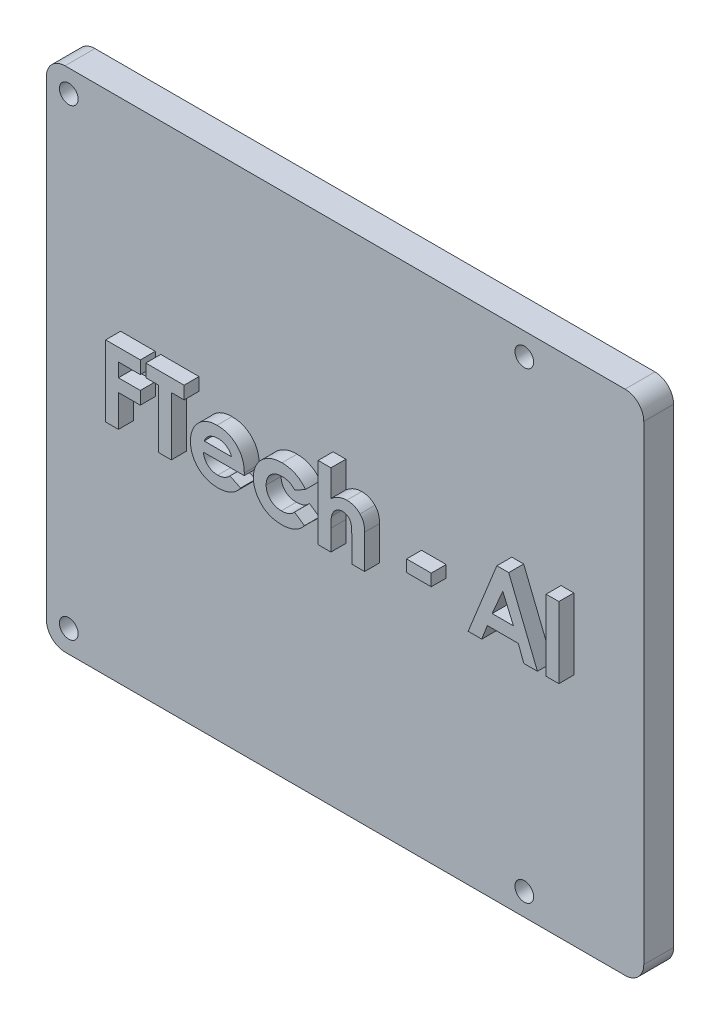
from build123d import *

# Parameters (mm, degrees)
SKETCH1_W           = 80
SKETCH1_H           = 68
BOSS_EXTRUDE1_DEPTH = 4
SKETCH2_W           = 3.297115384
SKETCH2_H           = 1.5875
SKETCH2_W_2         = 1.709615384
SKETCH2_H_2         = 9.525
BOSS_EXTRUDE2_DEPTH = 2
SKETCH3_R           = 1.25
CUT_EXTRUDE1_DEPTH  = 10
FILLET1_R           = 2.5


with BuildPart() as part:
    # Sketch1 → Boss-Extrude1 (new body)
    with BuildSketch(Plane.XY):
        with Locations((40, -34)):
            Rectangle(SKETCH1_W, SKETCH1_H)
    extrude(amount=BOSS_EXTRUDE1_DEPTH)

    # Sketch2 → Boss-Extrude2 (add)
    with BuildSketch(Plane.XY.offset(4)):
        Polygon((9.941146253, -27.067496964), (14.581530868, -27.067496964), (14.581530868, -28.777112348), (11.650761637, -28.777112348), (11.650761637, -30.608843117), (14.581530868, -30.608843117), (14.581530868, -32.318458502), (11.650761637, -32.318458502), (11.650761637, -36.592496964), (9.941146253, -36.592496964), align=None)
        Polygon((15.314223176, -27.067496964), (20.44306933, -27.067496964), (20.44306933, -28.777112348), (18.733453945, -28.777112348), (18.733453945, -36.592496964), (17.02383856, -36.592496964), (17.02383856, -28.777112348), (15.314223176, -28.777112348), align=None)
        with BuildLine():
            Line((28.496960556, -33.539612348), (23.007492406, -33.539612348))
            add(Edge.make_bspline(
                [(23.007492406, -33.539612348), (23.018684989, -33.603396854), (23.040679296, -33.72873844), (23.088440716, -33.910807969), (23.149391451, -34.082387221), (23.222437069, -34.243705554), (23.306346021, -34.395615795), (23.404218861, -34.537405426), (23.514814163, -34.668949208), (23.637492493, -34.789675439), (23.770209026, -34.897848759), (23.912320137, -34.992615425), (24.063972474, -35.070318294), (24.223427402, -35.13581375), (24.391876415, -35.187692785), (24.569567428, -35.22347277), (24.756029409, -35.244608138), (24.883053007, -35.247665127), (24.94798219, -35.249227733)],
                knots=[0, 0, 0, 0, 0.000194219, 0.000381655, 0.000563912, 0.000739826, 0.000912365, 0.001083845, 0.001255835, 0.001427188, 0.001599432, 0.001768776, 0.001938603, 0.002109744, 0.002285378, 0.002466493, 0.00265276, 0.002847531, 0.002847531, 0.002847531, 0.002847531], degree=3))
            add(Edge.make_bspline(
                [(24.94798219, -35.249227733), (25.026356122, -35.247158585), (25.180697476, -35.243083824), (25.406808708, -35.206946748), (25.625491206, -35.152363282), (25.834675464, -35.071193087), (26.036784552, -34.970150463), (26.228491135, -34.844263786), (26.413113502, -34.697211877), (26.525754903, -34.583864321), (26.583183512, -34.52607569)],
                knots=[0, 0, 0, 0, 0.00023497, 0.000462724, 0.000685321, 0.000909986, 0.001134407, 0.001361978, 0.001596793, 0.001841031, 0.001841031, 0.001841031, 0.001841031], degree=3))
            Line((26.583183512, -34.52607569), (28.014223176, -35.207250569))
            add(Edge.make_bspline(
                [(28.014223176, -35.207250569), (27.969167727, -35.269510284), (27.879892013, -35.39287562), (27.734152405, -35.566482509), (27.582063844, -35.728464779), (27.423512902, -35.877757048), (27.258298498, -36.013933893), (27.086880218, -36.138654193), (26.906752853, -36.248569258), (26.721518018, -36.348996714), (26.527346566, -36.435092705), (26.324775856, -36.508512328), (26.114663887, -36.574883042), (25.8943574, -36.62545389), (25.665690885, -36.665485362), (25.428117326, -36.693913009), (25.181668035, -36.711471405), (25.014157888, -36.713552931), (24.928901661, -36.714612348)],
                knots=[0, 0, 0, 0, 0.000230496, 0.000456719, 0.000679438, 0.000896764, 0.001109552, 0.001321381, 0.001532132, 0.00174213, 0.001953106, 0.002168615, 0.002388298, 0.002613691, 0.002846137, 0.00308446, 0.003331197, 0.00358694, 0.00358694, 0.00358694, 0.00358694], degree=3))
            add(Edge.make_bspline(
                [(24.928901661, -36.714612348), (24.797736356, -36.711938282), (24.540856666, -36.706701278), (24.165123683, -36.658094386), (23.808281562, -36.577498918), (23.469322706, -36.467941759), (23.149712321, -36.323291987), (22.849292231, -36.146373316), (22.56506081, -35.940577633), (22.305702913, -35.701585832), (22.069420218, -35.441457465), (21.861884189, -35.162097362), (21.688220996, -34.865457307), (21.545605289, -34.553500525), (21.434759407, -34.22542853), (21.354845956, -33.881098157), (21.305858053, -33.520673865), (21.300567116, -33.275184689), (21.297877022, -33.15036956)],
                knots=[0, 0, 0, 0, 0.000393355, 0.000770363, 0.001134197, 0.001489592, 0.001837156, 0.002184364, 0.002533949, 0.002887809, 0.003240386, 0.003586896, 0.003929847, 0.004269674, 0.004614208, 0.004966883, 0.005328755, 0.005703044, 0.005703044, 0.005703044, 0.005703044], degree=3))
            add(Edge.make_bspline(
                [(21.297877022, -33.15036956), (21.300593592, -33.022382718), (21.305938322, -32.770574356), (21.35442417, -32.401827702), (21.43498034, -32.049993519), (21.546150471, -31.714587295), (21.68660268, -31.394560022), (21.862475439, -31.092711555), (22.069317229, -30.807991022), (22.304748721, -30.541730376), (22.565205337, -30.301401052), (22.841965099, -30.087219597), (23.138137687, -29.908749392), (23.450373133, -29.764545577), (23.776674267, -29.647383618), (24.120812674, -29.569422118), (24.480169985, -29.517075639), (24.725818729, -29.512254854), (24.850671493, -29.509804656)],
                knots=[0, 0, 0, 0, 0.000383822, 0.000755153, 0.001113405, 0.001465176, 0.001813702, 0.002159949, 0.002511078, 0.002867919, 0.003224363, 0.00357279, 0.003916054, 0.004259212, 0.004603191, 0.004954008, 0.005316137, 0.005690426, 0.005690426, 0.005690426, 0.005690426], degree=3))
            add(Edge.make_bspline(
                [(24.850671493, -29.509804656), (24.982465169, -29.512520208), (25.241228469, -29.517851915), (25.619578317, -29.56606413), (25.978789826, -29.647151059), (26.320393439, -29.755760898), (26.640026738, -29.904064675), (26.944713035, -30.076629658), (27.227144226, -30.286873771), (27.490330725, -30.524696023), (27.727910328, -30.78855157), (27.935581226, -31.075179507), (28.1122836, -31.381782514), (28.255502629, -31.709603931), (28.366234692, -32.057659606), (28.446222118, -32.425497521), (28.49483636, -32.814516755), (28.500028844, -33.08090052), (28.502684714, -33.217151411)],
                knots=[0, 0, 0, 0, 0.000395262, 0.000776056, 0.00114175, 0.001498959, 0.001849049, 0.002196948, 0.002547662, 0.002902934, 0.003259622, 0.003610751, 0.003962909, 0.004319189, 0.004681845, 0.005056854, 0.005447115, 0.005855723, 0.005855723, 0.005855723, 0.005855723], degree=3))
            Line((28.502684714, -33.217151411), (28.496960556, -33.539612348))
        make_face()
        with BuildLine():
            add(Edge.make_bspline(
                [(26.79306933, -32.196343117), (26.760807842, -32.10928243), (26.696663599, -31.936183104), (26.551764426, -31.697348271), (26.359487859, -31.490507605), (26.135856418, -31.307389924), (25.880343493, -31.158760176), (25.601000745, -31.05114741), (25.301359012, -30.986621447), (25.095221646, -30.979053685), (24.989959354, -30.975189271)],
                knots=[0, 0, 0, 0, 0.000278144, 0.000553023, 0.000831285, 0.001121535, 0.001417375, 0.001713959, 0.002016336, 0.002331864, 0.002331864, 0.002331864, 0.002331864], degree=3))
            add(Edge.make_bspline(
                [(24.989959354, -30.975189271), (24.874995792, -30.978901511), (24.650265967, -30.986158166), (24.326108495, -31.063335357), (24.020338864, -31.178520011), (23.840074419, -31.297277834), (23.749724979, -31.356799848)],
                knots=[0, 0, 0, 0, 0.000344212, 0.000672863, 0.000994939, 0.001318572, 0.001318572, 0.001318572, 0.001318572], degree=3))
            add(Edge.make_bspline(
                [(23.749724979, -31.356799848), (23.693353676, -31.402133118), (23.57317294, -31.498781331), (23.417093872, -31.691585342), (23.263354692, -31.925027717), (23.175945491, -32.102343693), (23.129607791, -32.196343117)],
                knots=[0, 0, 0, 0, 0.000216478, 0.00046152, 0.000739886, 0.001053945, 0.001053945, 0.001053945, 0.001053945], degree=3))
            Line((23.129607791, -32.196343117), (26.79306933, -32.196343117))
        make_face(mode=Mode.SUBTRACT)
        with BuildLine():
            Line((36.684415483, -31.051511387), (35.268640243, -31.829996964))
            add(Edge.make_bspline(
                [(35.268640243, -31.829996964), (35.203746266, -31.765011363), (35.079003727, -31.640092701), (34.878969041, -31.481965493), (34.682508712, -31.351040564), (34.481523494, -31.254424691), (34.274216817, -31.181663679), (34.053111382, -31.133472462), (33.815626499, -31.101740258), (33.651357935, -31.098813674), (33.56665707, -31.097304656)],
                knots=[0, 0, 0, 0, 0.000275289, 0.000529175, 0.000763625, 0.000982086, 0.001196307, 0.001421272, 0.001659832, 0.001913782, 0.001913782, 0.001913782, 0.001913782], degree=3))
            add(Edge.make_bspline(
                [(33.56665707, -31.097304656), (33.488980531, -31.099180831), (33.336974058, -31.102852348), (33.11486848, -31.130276065), (32.903779888, -31.173348266), (32.704087196, -31.236363048), (32.51614608, -31.319609004), (32.338402345, -31.418118071), (32.172583194, -31.535737881), (32.021032525, -31.670796497), (31.884231409, -31.81949304), (31.762197834, -31.978084293), (31.662223518, -32.14892292), (31.575789521, -32.327993595), (31.512242192, -32.518659664), (31.46574942, -32.719191032), (31.439248973, -32.929596582), (31.435409526, -33.073339519), (31.433453945, -33.146553454)],
                knots=[0, 0, 0, 0, 0.000232978, 0.000455918, 0.000670343, 0.000878531, 0.001082728, 0.001286032, 0.001487212, 0.001691302, 0.001893843, 0.002092666, 0.002290313, 0.00248662, 0.002688152, 0.002891805, 0.003103384, 0.003323017, 0.003323017, 0.003323017, 0.003323017], degree=3))
            add(Edge.make_bspline(
                [(31.433453945, -33.146553454), (31.435520185, -33.217856747), (31.439554665, -33.357081476), (31.464341152, -33.561635782), (31.507371426, -33.756362753), (31.57188969, -33.940232923), (31.649222041, -34.114941316), (31.746337318, -34.27909844), (31.860539534, -34.433421128), (31.992429916, -34.576568092), (32.13853099, -34.705311222), (32.296039404, -34.819004735), (32.464485217, -34.9153958), (32.645830655, -34.991041123), (32.837119063, -35.052676237), (33.039627872, -35.09656285), (33.253141579, -35.120922956), (33.398688467, -35.125017325), (33.473162479, -35.127112348)],
                knots=[0, 0, 0, 0, 0.000213915, 0.000417684, 0.000617192, 0.000810885, 0.001001327, 0.001189491, 0.001381826, 0.001576279, 0.001772289, 0.00196504, 0.002158159, 0.00235308, 0.002553416, 0.002760376, 0.002973617, 0.003197063, 0.003197063, 0.003197063, 0.003197063], degree=3))
            add(Edge.make_bspline(
                [(33.473162479, -35.127112348), (33.564857836, -35.12501409), (33.743833851, -35.120918595), (34.004013035, -35.086181927), (34.248838086, -35.028739693), (34.47833497, -34.949235078), (34.692182614, -34.845281313), (34.889831553, -34.718309543), (35.073313612, -34.569256423), (35.180310241, -34.453051252), (35.234295291, -34.39442004)],
                knots=[0, 0, 0, 0, 0.000274998, 0.000536756, 0.000785748, 0.001028333, 0.00126386, 0.001497275, 0.00173181, 0.001970653, 0.001970653, 0.001970653, 0.001970653], degree=3))
            Line((35.234295291, -34.39442004), (36.562300099, -35.306469319))
            add(Edge.make_bspline(
                [(36.562300099, -35.306469319), (36.470249184, -35.419013203), (36.288593704, -35.641109999), (35.971655264, -35.927384661), (35.630533773, -36.173358206), (35.258368542, -36.369691173), (34.860579527, -36.525848949), (34.434058388, -36.636236994), (33.979526557, -36.701217732), (33.667362093, -36.710076109), (33.507507431, -36.714612348)],
                knots=[0, 0, 0, 0, 0.000435647, 0.000859715, 0.001276934, 0.001694348, 0.002118477, 0.002556283, 0.003013121, 0.003492589, 0.003492589, 0.003492589, 0.003492589], degree=3))
            add(Edge.make_bspline(
                [(33.507507431, -36.714612348), (33.363628321, -36.71128629), (33.082616555, -36.704790132), (32.673048887, -36.655041817), (32.287829229, -36.571247551), (31.926165123, -36.454874539), (31.588386303, -36.304127912), (31.275588215, -36.117145769), (30.985661043, -35.899129271), (30.723836235, -35.649048519), (30.490228431, -35.37683292), (30.286287975, -35.090146613), (30.109910941, -34.794126183), (29.971543329, -34.483844482), (29.858458856, -34.164137778), (29.782085152, -33.831184433), (29.73171199, -33.487727026), (29.726484161, -33.254858734), (29.72383856, -33.13701319)],
                knots=[0, 0, 0, 0, 0.000431562, 0.000842888, 0.001235488, 0.001612612, 0.001980708, 0.002342625, 0.00270363, 0.003066687, 0.003426587, 0.00377815, 0.004121101, 0.0044584, 0.004795716, 0.005136809, 0.005481666, 0.005834986, 0.005834986, 0.005834986, 0.005834986], degree=3))
            add(Edge.make_bspline(
                [(29.72383856, -33.13701319), (29.725255828, -33.054909199), (29.728062998, -32.892286439), (29.752027358, -32.650773504), (29.789307849, -32.413358949), (29.845336026, -32.181709296), (29.914240793, -31.954700667), (29.998003867, -31.732378695), (30.099929174, -31.515890597), (30.213627163, -31.303394798), (30.343211206, -31.100500871), (30.484584709, -30.907298364), (30.637548489, -30.724970555), (30.803899484, -30.555216687), (30.98247779, -30.396822106), (31.170687339, -30.246573277), (31.374618503, -30.112218878), (31.587181845, -29.985900927), (31.810208382, -29.873453621), (32.041134725, -29.776396771), (32.278176332, -29.693932979), (32.521901379, -29.627630426), (32.771263748, -29.572984967), (33.028482324, -29.538304713), (33.291429057, -29.513928707), (33.469288487, -29.511187627), (33.559024858, -29.509804656)],
                knots=[0, 0, 0, 0, 0.000246257, 0.00048776, 0.000727416, 0.000966685, 0.00120208, 0.001438801, 0.001678678, 0.001919433, 0.002161335, 0.002400238, 0.002637213, 0.002874687, 0.003112529, 0.003353012, 0.003596444, 0.003844491, 0.004094511, 0.004345055, 0.004595476, 0.004846832, 0.005102433, 0.005360669, 0.005624974, 0.005894118, 0.005894118, 0.005894118, 0.005894118], degree=3))
            add(Edge.make_bspline(
                [(33.559024858, -29.509804656), (33.642378435, -29.510747039), (33.806769312, -29.512605618), (34.049537479, -29.532039641), (34.285683422, -29.565049185), (34.515609021, -29.60871942), (34.740012554, -29.662834448), (34.95588642, -29.734967966), (35.166181978, -29.816836792), (35.437044878, -29.940450172), (35.756342662, -30.12496315), (36.106846083, -30.389595434), (36.419362315, -30.69917661), (36.595594832, -30.933442229), (36.684415483, -31.051511387)],
                knots=[0, 0, 0, 0, 0.00025002, 0.000493093, 0.000730015, 0.000965023, 0.001195021, 0.001421894, 0.001647247, 0.001871798, 0.002314602, 0.002750407, 0.0031862, 0.003629016, 0.003629016, 0.003629016, 0.003629016], degree=3))
        make_face()
        with BuildLine():
            Line((38.394030868, -26.823266194), (40.103646253, -26.823266194))
            Line((40.103646253, -26.823266194), (40.103646253, -30.38560093))
            add(Edge.make_bspline(
                [(40.103646253, -30.38560093), (40.189763203, -30.315565539), (40.357620062, -30.179054426), (40.620992977, -30.001212838), (40.883821137, -29.849452786), (41.148893537, -29.72646164), (41.415060196, -29.630080681), (41.68278074, -29.561728914), (41.952312901, -29.516884122), (42.133003233, -29.512166995), (42.223493007, -29.509804656)],
                knots=[0, 0, 0, 0, 0.000332861, 0.000648804, 0.000952208, 0.001242458, 0.001524314, 0.001800132, 0.002070537, 0.00234181, 0.00234181, 0.00234181, 0.00234181], degree=3))
            add(Edge.make_bspline(
                [(42.223493007, -29.509804656), (42.310085648, -29.51210232), (42.480074273, -29.516612828), (42.729457892, -29.549192867), (42.968317597, -29.605254714), (43.197241807, -29.682321442), (43.414655568, -29.785964838), (43.623386104, -29.90736999), (43.820952373, -30.052824718), (43.941160194, -30.164948317), (44.001798296, -30.221508382)],
                knots=[0, 0, 0, 0, 0.000259748, 0.000509906, 0.000752889, 0.000994851, 0.001232999, 0.001474177, 0.001718415, 0.001967034, 0.001967034, 0.001967034, 0.001967034], degree=3))
            add(Edge.make_bspline(
                [(44.001798296, -30.221508382), (44.051598185, -30.274358583), (44.151920509, -30.380825788), (44.276869286, -30.564372791), (44.384761308, -30.764301023), (44.472677924, -30.982489196), (44.538062863, -31.219038875), (44.588684064, -31.472001327), (44.616678665, -31.744138616), (44.620133586, -31.931699016), (44.621915483, -32.028434464)],
                knots=[0, 0, 0, 0, 0.00021756, 0.000438276, 0.000663653, 0.000898211, 0.001142218, 0.001398921, 0.001671372, 0.001961553, 0.001961553, 0.001961553, 0.001961553], degree=3))
            Line((44.621915483, -32.028434464), (44.621915483, -36.592496964))
            Line((44.621915483, -36.592496964), (42.912300099, -36.592496964))
            Line((42.912300099, -36.592496964), (42.912300099, -33.566325089))
            add(Edge.make_bspline(
                [(42.912300099, -33.566325089), (42.911967917, -33.470283529), (42.911332086, -33.286450076), (42.905622316, -33.022460412), (42.896298082, -32.782635894), (42.883546767, -32.566904047), (42.865743144, -32.37616645), (42.84823203, -32.209055968), (42.823659834, -32.066373624), (42.786866085, -31.911335696), (42.726987513, -31.745510121), (42.6399742, -31.568747185), (42.523748323, -31.422863435), (42.389245612, -31.302545916), (42.233729039, -31.210715033), (42.062765945, -31.142890338), (41.87343362, -31.104747406), (41.742196972, -31.099850372), (41.673973777, -31.097304656)],
                knots=[0, 0, 0, 0, 0.000288122, 0.000551496, 0.0007921, 0.001008123, 0.001199699, 0.001366793, 0.001512031, 0.001633743, 0.001844365, 0.002039789, 0.002221866, 0.002400286, 0.002578299, 0.002760775, 0.002949749, 0.003154347, 0.003154347, 0.003154347, 0.003154347], degree=3))
            add(Edge.make_bspline(
                [(41.673973777, -31.097304656), (41.585099165, -31.100779057), (41.411028219, -31.107584064), (41.161402781, -31.177633468), (40.931156155, -31.288355445), (40.722975533, -31.441811122), (40.541568213, -31.634020468), (40.389576874, -31.859309018), (40.265256281, -32.115423396), (40.211522682, -32.30218643), (40.183784474, -32.398596723)],
                knots=[0, 0, 0, 0, 0.000266049, 0.000521086, 0.000771128, 0.001029111, 0.001292291, 0.001560078, 0.001841702, 0.002142207, 0.002142207, 0.002142207, 0.002142207], degree=3))
            add(Edge.make_bspline(
                [(40.183784474, -32.398596723), (40.176877601, -32.428395742), (40.16112767, -32.496347257), (40.149066075, -32.612284213), (40.131166859, -32.752432125), (40.124957908, -32.917630837), (40.113327072, -33.107625546), (40.109144166, -33.322723651), (40.104933042, -33.563127373), (40.104088971, -33.731686367), (40.103646253, -33.820096122)],
                knots=[0, 0, 0, 0, 9.1686e-05, 0.000209074, 0.000349196, 0.00051547, 0.000704608, 0.000920294, 0.001160739, 0.001425965, 0.001425965, 0.001425965, 0.001425965], degree=3))
            Line((40.103646253, -33.820096122), (40.103646253, -36.592496964))
            Line((40.103646253, -36.592496964), (38.394030868, -36.592496964))
            Line((38.394030868, -36.592496964), (38.394030868, -26.823266194))
        make_face()
        with Locations((51.887780868, -33.112208502)):
            Rectangle(SKETCH2_W, SKETCH2_H)
        Polygon((62.330554306, -27.067496964), (63.916146253, -27.067496964), (67.762780868, -36.592496964), (65.936774257, -36.592496964), (65.196449738, -34.63865081), (61.046434714, -34.63865081), (60.306110195, -36.592496964), (58.482011637, -36.592496964), align=None)
        Polygon((63.122396253, -29.622379776), (61.695172695, -32.929035425), (64.54961981, -32.929035425), align=None, mode=Mode.SUBTRACT)
        with Locations((69.777684714, -31.829996964)):
            Rectangle(SKETCH2_W_2, SKETCH2_H_2)
    extrude(amount=BOSS_EXTRUDE2_DEPTH)

    # Sketch3 → Cut-Extrude1 (cut)
    with BuildSketch(Plane.XY.offset(4)):
        with Locations((3, -3)):
            Circle(SKETCH3_R)
        with Locations((3, -65)):
            Circle(SKETCH3_R)
        with Locations((64, -65)):
            Circle(SKETCH3_R)
        with Locations((64, -3)):
            Circle(SKETCH3_R)
    extrude(amount=-CUT_EXTRUDE1_DEPTH, mode=Mode.SUBTRACT)

    # Fillet1
    fillet1_edges = [part.edges().sort_by_distance(p)[0] for p in [
        (0, 0, 2),
        (80, 0, 2),
        (80, -68, 2),
        (0, -68, 2),
    ]]
    fillet(fillet1_edges, radius=FILLET1_R)


solid = part.part
